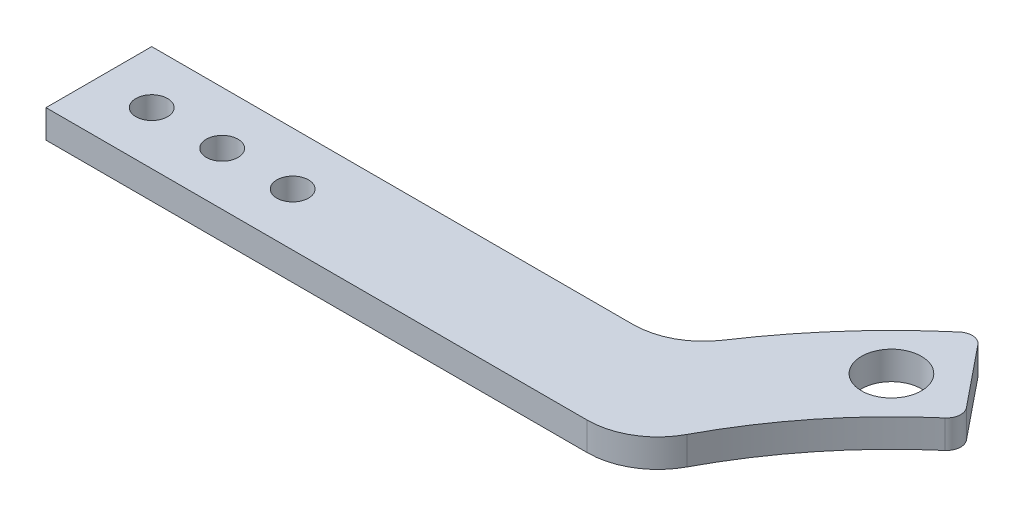
from build123d import *

# Parameters (mm, degrees)
SKETCH1_R           = 85
BOSS_EXTRUDE1_DEPTH = 4
SKETCH2_R           = 4.25
CUT_EXTRUDE1_DEPTH  = 5
CUT_EXTRUDE2_DEPTH  = 5
SKETCH5_W           = 42.180521306
SKETCH5_H           = 70
CUT_EXTRUDE4_DEPTH  = 5
SKETCH6_W           = 106.727452964
SKETCH6_H           = 15
BOSS_EXTRUDE3_DEPTH = 4
SKETCH7_R           = 70
CUT_EXTRUDE5_DEPTH  = 5
SKETCH8_R           = 2.25
CUT_EXTRUDE6_DEPTH  = 5
LPATTERN1_COUNT     = 3
LPATTERN1_PITCH     = 10
FILLET1_R           = 10
FILLET2_R           = 2


with BuildPart() as part:
    # Sketch1 → Boss-Extrude1 (new body)
    with BuildSketch(Plane(origin=(0, 0, 0), x_dir=(1, 0, 0), z_dir=(0, 1, 0))):
        Circle(SKETCH1_R)
    extrude(amount=BOSS_EXTRUDE1_DEPTH)

    # Sketch2 → Cut-Extrude1 (cut, through all)
    with BuildSketch(Plane(origin=(0, 4, 0), x_dir=(1, 0, 0), z_dir=(0, 1, 0))):
        with Locations((-54.800775542, 54.800775542)):
            Circle(SKETCH2_R)
    extrude(amount=-CUT_EXTRUDE1_DEPTH, mode=Mode.SUBTRACT)

    # Sketch3 → Cut-Extrude2 (cut, through all)
    with BuildSketch(Plane(origin=(0, 4, 0), x_dir=(1, 0, 0), z_dir=(0, 1, 0))):
        with BuildLine():
            Line((0, 0), (-85, 0))
            ThreePointArc((-85, 0), (76.71974917, -36.593443229), (-53.492233239, 66.057406724))
            Line((-53.492233239, 66.057406724), (0, 0))
        make_face()
    extrude(amount=-CUT_EXTRUDE2_DEPTH, mode=Mode.SUBTRACT)

    # Sketch5 → Cut-Extrude4 (cut, through all)
    with BuildSketch(Plane(origin=(0, 0, 0), x_dir=(1, 0, 0), z_dir=(0, 1, 0))):
        with Locations((-74.50134639, 0)):
            Rectangle(SKETCH5_W, SKETCH5_H)
    extrude(amount=CUT_EXTRUDE4_DEPTH, mode=Mode.SUBTRACT)

    # Sketch6 → Boss-Extrude3 (add)
    with BuildSketch(Plane(origin=(0, 0, 0), x_dir=(1, 0, 0), z_dir=(0, 1, 0))):
        with Locations((-94.095940442, 35)):
            Rectangle(SKETCH6_W, SKETCH6_H)
    extrude(amount=BOSS_EXTRUDE3_DEPTH)

    # Sketch7 → Cut-Extrude5 (cut, through all)
    with BuildSketch(Plane(origin=(0, 0, 0), x_dir=(1, 0, 0), z_dir=(0, 1, 0))):
        Circle(SKETCH7_R)
    extrude(amount=CUT_EXTRUDE5_DEPTH, mode=Mode.SUBTRACT)

    # Sketch8 → Cut-Extrude6 (cut, through all)
    with BuildSketch(Plane(origin=(0, 4, 0), x_dir=(1, 0, 0), z_dir=(0, 1, 0))):
        with Locations((-139.959666924, 35)):
            Circle(SKETCH8_R)
    cut_extrude6 = extrude(amount=-CUT_EXTRUDE6_DEPTH, mode=Mode.SUBTRACT)

    # LPattern1: Cut-Extrude6 ×3
    with Locations(*[(i * LPATTERN1_PITCH, 0, 0) for i in range(1, LPATTERN1_COUNT)]):
        add(cut_extrude6, mode=Mode.SUBTRACT)

    # Fillet1
    fillet1_edges = [part.edges().sort_by_distance(p)[0] for p in [
        (-73.612159322, 2, -42.5),
        (-64.371965948, 2, -27.5),
    ]]
    fillet(fillet1_edges, radius=FILLET1_R)

    # Fillet2
    fillet2_edges = [part.edges().sort_by_distance(p)[0] for p in [
        (-53.492233239, 2, -66.057406724),
        (-44.052427373, 2, -54.400217302),
    ]]
    fillet(fillet2_edges, radius=FILLET2_R)


solid = part.part
